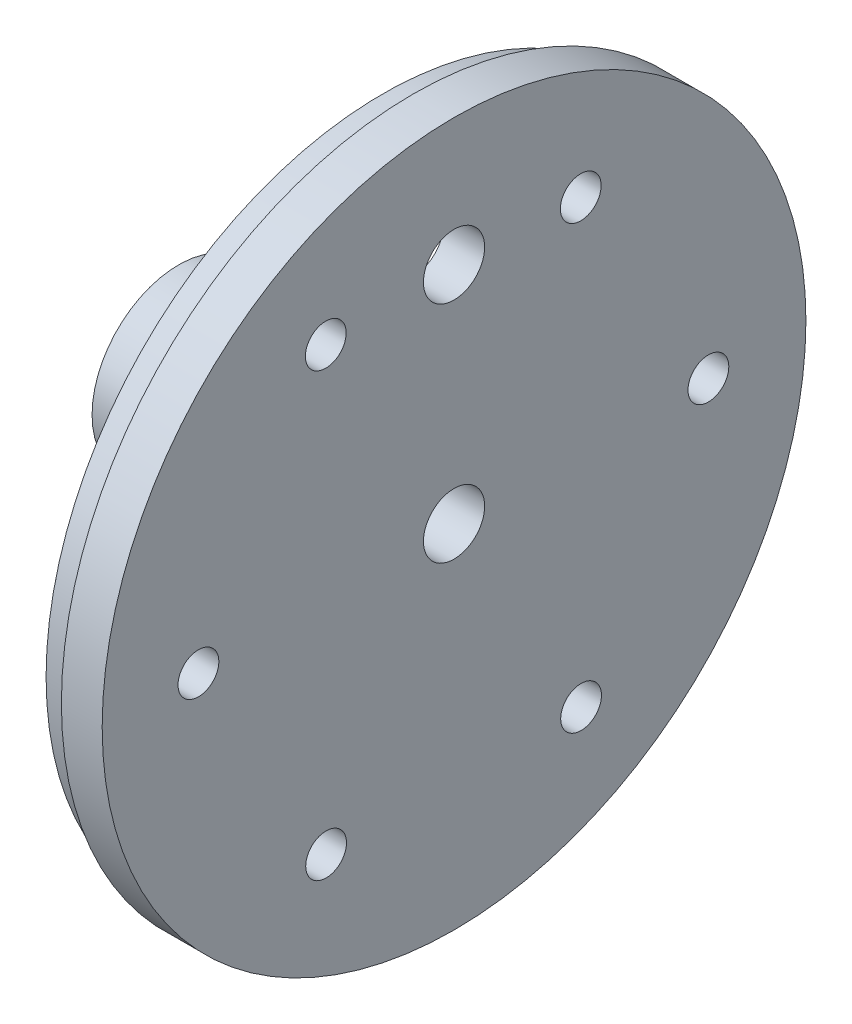
from build123d import *

# Parameters (mm, degrees)
SKETCH1_R           = 34.5
BOSS_EXTRUDE1_DEPTH = 2
SKETCH2_R           = 8.49
BOSS_EXTRUDE2_DEPTH = 23
SKETCH4_R           = 3
CUT_EXTRUDE1_DEPTH  = 30
CUT_EXTRUDE2_REACH  = 45
SKETCH5_R           = 1.5
CUT_EXTRUDE3_REACH  = 36.5
SKETCH6_R           = 1.5
SKETCH19_R          = 33
SKETCH19_R_2        = 30
BOSS_EXTRUDE5_DEPTH = 3
SKETCH21_R          = 3
CUT_EXTRUDE6_DEPTH  = 10
SKETCH20_R          = 2
CUT_EXTRUDE7_DEPTH  = 10


with BuildPart() as part:
    # Sketch1 → Boss-Extrude1 (new body, symmetric)
    with BuildSketch(Plane(origin=(0, 0, 0), x_dir=(0, 0, -1), z_dir=(1, 0, 0))):
        Circle(SKETCH1_R)
    extrude(amount=BOSS_EXTRUDE1_DEPTH, both=True)

    # Sketch2 → Boss-Extrude2 (add)
    with BuildSketch(Plane.ZY.offset(2)):
        Circle(SKETCH2_R)
    extrude(amount=BOSS_EXTRUDE2_DEPTH)

    # Sketch4 → Cut-Extrude1 (cut)
    with BuildSketch(Plane.ZY.offset(25)):
        Circle(SKETCH4_R)
    extrude(amount=-CUT_EXTRUDE1_DEPTH, mode=Mode.SUBTRACT)

    # Sketch5 → Cut-Extrude2 (cut, up to next)
    with BuildSketch(Plane(origin=(0, 8.5, 0), x_dir=(1, 0, 0), z_dir=(0, 1, 0)), mode=Mode.PRIVATE) as cut_extrude2_sk1:
        with Locations((-19.5, 0)):
            Circle(SKETCH5_R)
    cut_extrude2_tool1 = extrude(cut_extrude2_sk1.sketch, amount=-CUT_EXTRUDE2_REACH, mode=Mode.PRIVATE) & part.part
    add(cut_extrude2_tool1.solids().sort_by_distance((-19.5, 8.5, 0))[0], mode=Mode.SUBTRACT)

    # Sketch6 → Cut-Extrude3 (cut, up to next)
    with BuildSketch(Plane.XY, mode=Mode.PRIVATE) as cut_extrude3_sk1:
        with Locations((-19.5, 0)):
            Circle(SKETCH6_R)
    cut_extrude3_tool1 = extrude(cut_extrude3_sk1.sketch, amount=-CUT_EXTRUDE3_REACH, mode=Mode.PRIVATE) & part.part
    add(cut_extrude3_tool1.solids().sort_by_distance((-19.5, 0, 0))[0], mode=Mode.SUBTRACT)

    # Sketch19 → Boss-Extrude5 (add)
    with BuildSketch(Plane.ZY.offset(2)):
        Circle(SKETCH19_R)
        Circle(SKETCH19_R_2, mode=Mode.SUBTRACT)
    extrude(amount=BOSS_EXTRUDE5_DEPTH)

    # Sketch21 → Cut-Extrude6 (cut)
    with BuildSketch(Plane.ZY.offset(2)):
        with Locations((0, 22)):
            Circle(SKETCH21_R)
    extrude(amount=-CUT_EXTRUDE6_DEPTH, mode=Mode.SUBTRACT)

    # Sketch20 → Cut-Extrude7 (cut)
    with BuildSketch(Plane.ZY.offset(2)):
        with Locations((-12.422389037, 21.516208963)):
            Circle(SKETCH20_R)
        with Locations((12.577603677, 21.497122149)):
            Circle(SKETCH20_R)
        with Locations((25.061070367, -0.163050043)):
            Circle(SKETCH20_R)
        with Locations((12.544544344, -21.804135421)):
            Circle(SKETCH20_R)
        with Locations((-12.45544837, -21.785048606)):
            Circle(SKETCH20_R)
        with Locations((-24.93891506, -0.124876414)):
            Circle(SKETCH20_R)
    extrude(amount=-CUT_EXTRUDE7_DEPTH, mode=Mode.SUBTRACT)


solid = part.part
